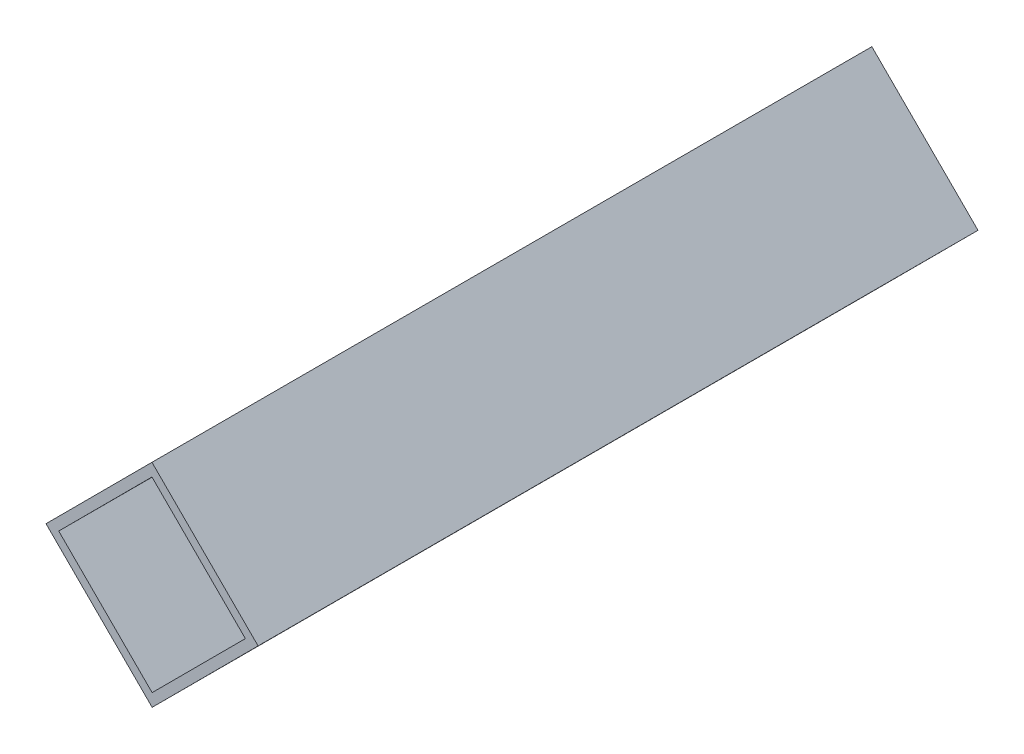
from build123d import *

# Parameters (mm, degrees)
EXTRUDE_1_DEPTH = 120


with BuildPart() as part:
    # 草圖1 → 填料-伸長1 (new body)
    with BuildSketch(Plane.XY):
        Polygon((0, 0), (17.69379362, -17.661530719), (0.032262901, -35.355324339), (-17.661530719, -17.69379362), align=None)
        Polygon((0.001935774, -2.12131946), (-15.540211259, -17.691857846), (0.030327127, -33.234004879), (15.57247416, -17.663466493), align=None, mode=Mode.SUBTRACT)
    extrude(amount=EXTRUDE_1_DEPTH)


solid = part.part
